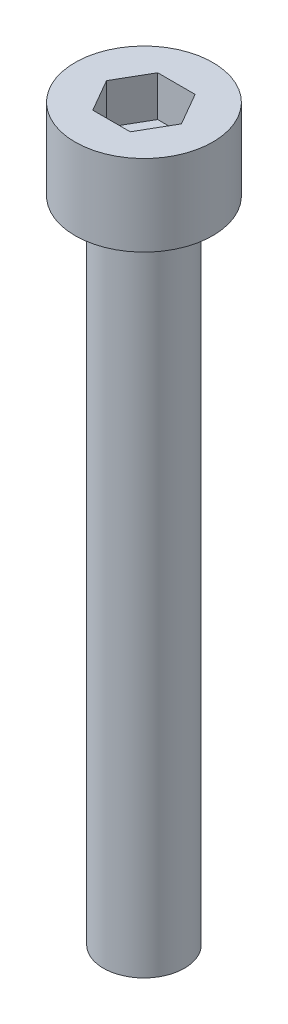
from build123d import *

# Parameters (mm, degrees)
SKETCH_1_R          = 4.25
EXTRUDE_1_DEPTH     = 5
CUT_EXTRUDE_1_DEPTH = 2.5
SKETCH_3_R          = 2.5
EXTRUDE_2_DEPTH     = 40


with BuildPart() as part:
    # 草图1 → 凸台-拉伸1 (new body)
    with BuildSketch(Plane(origin=(0, 0, 0), x_dir=(1, 0, 0), z_dir=(0, 1, 0))):
        Circle(SKETCH_1_R)
    extrude(amount=EXTRUDE_1_DEPTH)

    # 草图2 → 切除-拉伸1 (cut)
    with BuildSketch(Plane(origin=(0, 5, 0), x_dir=(1, 0, 0), z_dir=(0, 1, 0))):
        Polygon((2.309401077, 0), (1.154700538, 2), (-1.154700538, 2), (-2.309401077, 0), (-1.154700538, -2), (1.154700538, -2), align=None)
    extrude(amount=-CUT_EXTRUDE_1_DEPTH, mode=Mode.SUBTRACT)

    # 草图3 → 凸台-拉伸2 (add)
    with BuildSketch(Plane.XZ):
        Circle(SKETCH_3_R)
    extrude(amount=EXTRUDE_2_DEPTH)


solid = part.part
